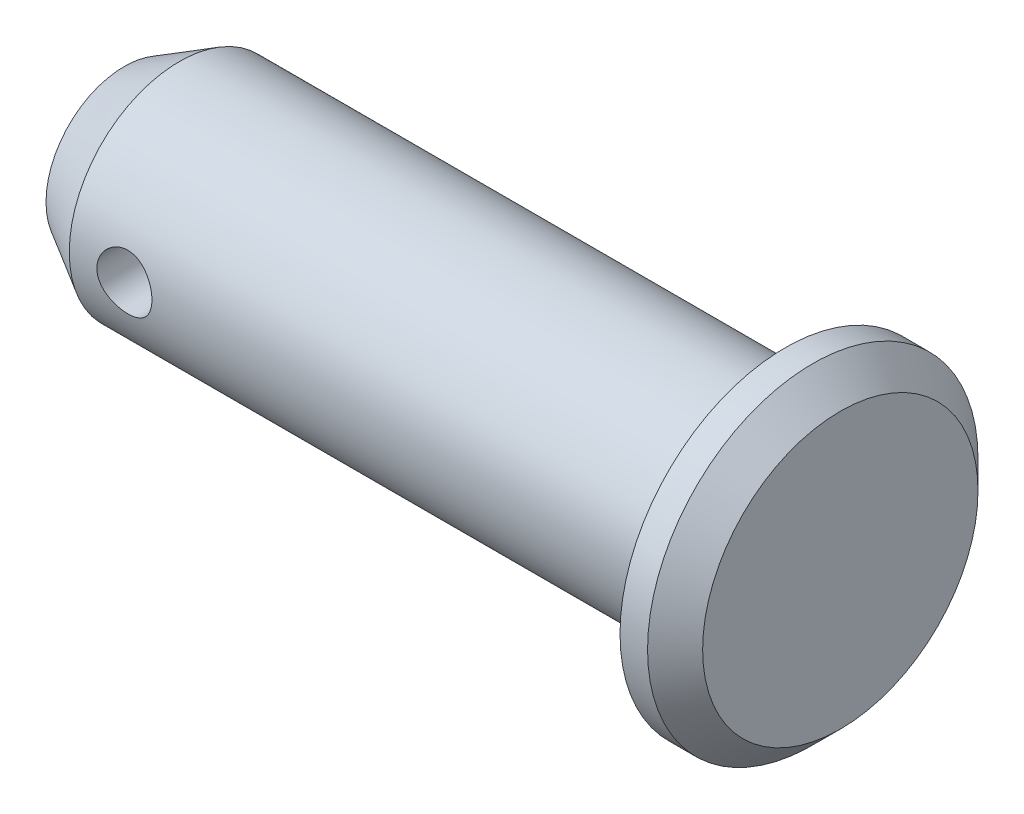
from build123d import *

# Parameters (mm, degrees)
SKETCH1_W              = 12
SKETCH1_H              = 2
HEAD_CHAMFER_SIZE      = 1
HEAD_CHAMFER_SIZE2     = 0.577350269
SKETCH21_R             = 0.5
R_CLIP_HOLE_DEPTH      = 4
R_CLIP_HOLE_DEPTH_BACK = 4


with BuildPart() as part:
    # Sketch1 → Body Revolve (revolve)
    with BuildSketch(Plane.XY):
        with Locations((-6, 1)):
            Rectangle(SKETCH1_W, SKETCH1_H)
    revolve(axis=Axis((0, 0, 0), (-1, 0, 0)))

    # Sketch14 → Head Revolve (revolve)
    with BuildSketch(Plane.XY):
        Polygon((0, 0), (1, 0), (1, 2.5), (0.5, 3), (0, 3), align=None)
    revolve(axis=Axis((0, 0, 0), (1, 0, 0)))

    # Head Chamfer
    head_chamfer_edges = [part.edges().sort_by_distance(p)[0] for p in [
        (-12, -2, 0),
    ]]
    head_chamfer_side = [part.faces().sort_by_distance(p)[0] for p in [
        (-6, -2, 0),
    ]]
    chamfer(head_chamfer_edges, length=HEAD_CHAMFER_SIZE, length2=HEAD_CHAMFER_SIZE2, reference=head_chamfer_side[0])

    # Sketch21 → R Clip Hole (cut, two sides)
    with BuildSketch(Plane.XY) as r_clip_hole_sk:
        with Locations((-10, 0)):
            Circle(SKETCH21_R)
    extrude(amount=R_CLIP_HOLE_DEPTH, mode=Mode.SUBTRACT)
    extrude(r_clip_hole_sk.sketch, amount=-R_CLIP_HOLE_DEPTH_BACK, mode=Mode.SUBTRACT)


solid = part.part
